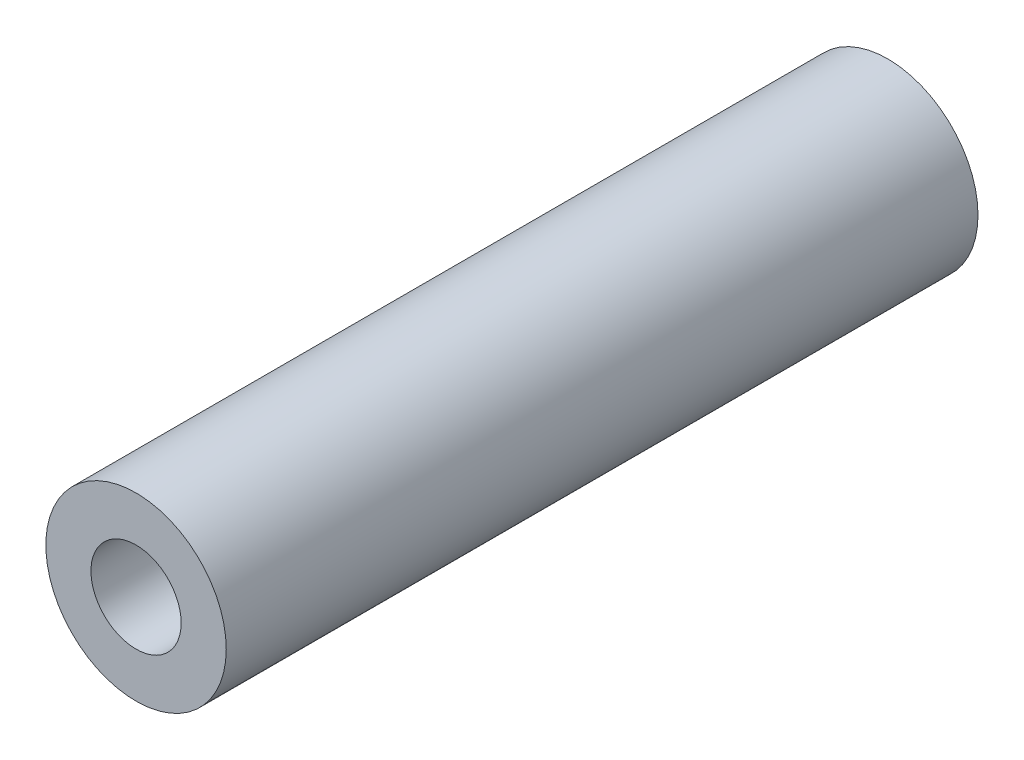
from build123d import *

# Parameters (mm, degrees)
SKETCH1_R           = 3
SKETCH1_R_2         = 1.5
BOSS_EXTRUDE1_DEPTH = 25


with BuildPart() as part:
    # Sketch1 → Boss-Extrude1 (new body)
    with BuildSketch(Plane.XY):
        Circle(SKETCH1_R)
        Circle(SKETCH1_R_2, mode=Mode.SUBTRACT)
    extrude(amount=BOSS_EXTRUDE1_DEPTH)


solid = part.part
